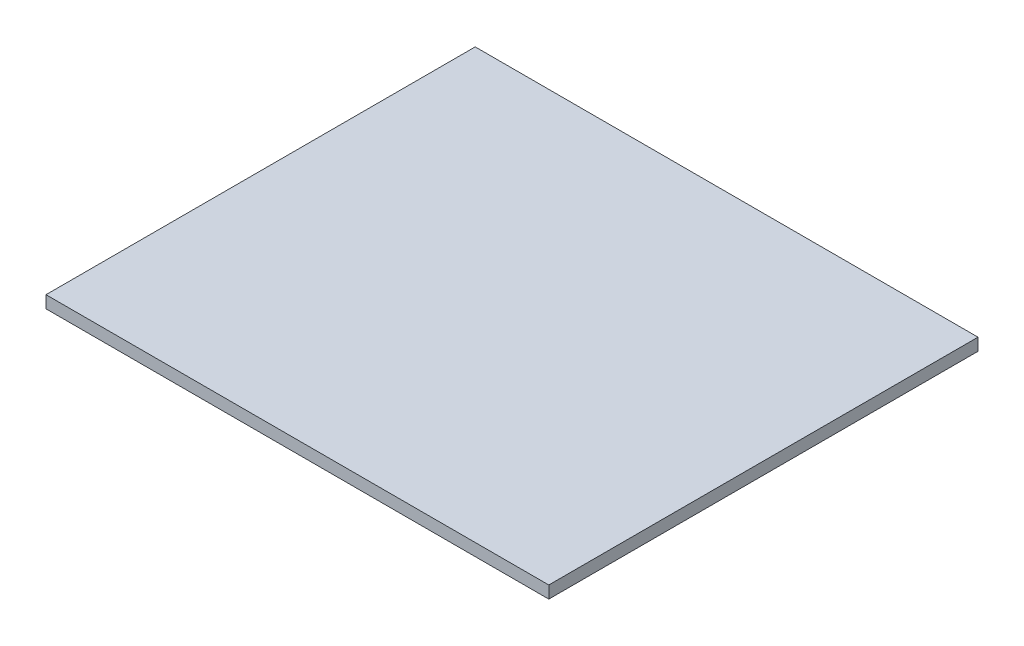
from build123d import *

# Parameters (mm, degrees)
SKETCH1_W       = 123
SKETCH1_H       = 105
BASEPLATE_DEPTH = 3


with BuildPart() as part:
    # Sketch1 → BasePlate (new body)
    with BuildSketch(Plane(origin=(0, 0, 0), x_dir=(1, 0, 0), z_dir=(0, 1, 0))):
        Rectangle(SKETCH1_W, SKETCH1_H)
    extrude(amount=BASEPLATE_DEPTH)


solid = part.part
